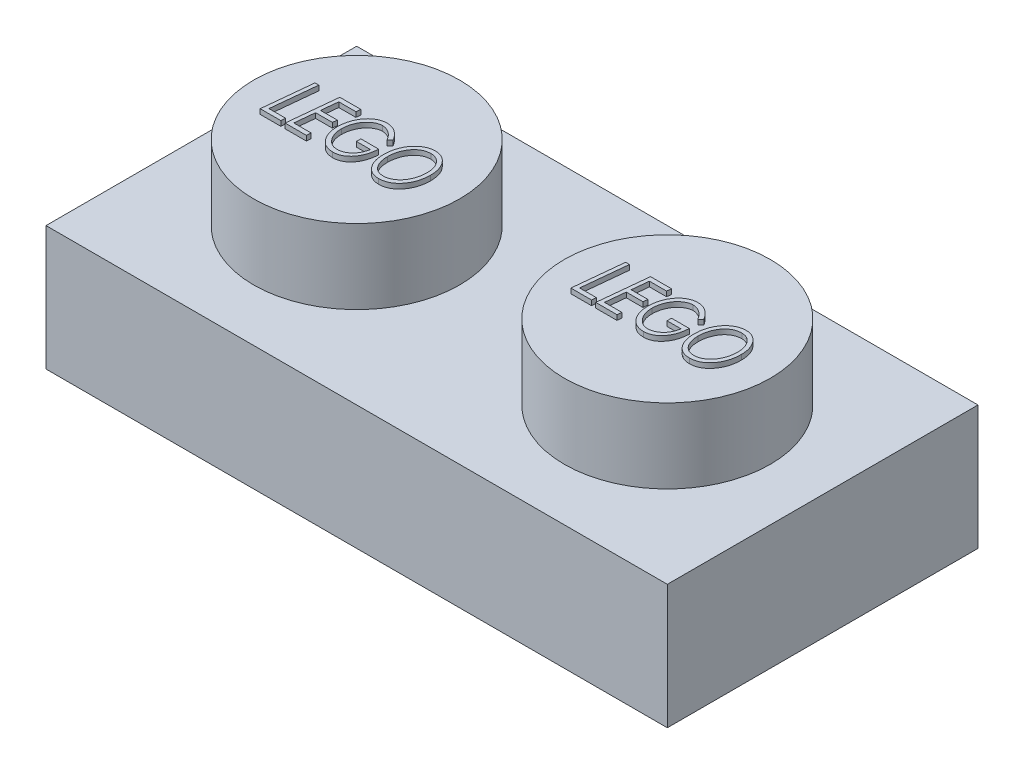
from build123d import *

# Parameters (mm, degrees)
SKETCH2_W           = 15.875
SKETCH2_H           = 7.9375
BOSS_EXTRUDE3_DEPTH = 3.175
SKETCH3_R           = 2.630752939
BOSS_EXTRUDE4_DEPTH = 1.905
LPATTERN1_COUNT     = 2
LPATTERN1_PITCH     = 7.9375
SHELL1_T            = -1.524
BOSS_EXTRUDE5_DEPTH = 0.127
LPATTERN2_COUNT     = 2
LPATTERN2_PITCH     = 7.9375
SKETCH5_R           = 1.4986
SKETCH5_R_2         = 0.635
BOSS_EXTRUDE6_DEPTH = 1.651


with BuildPart() as part:
    # Sketch2 → Boss-Extrude3 (new body)
    with BuildSketch(Plane(origin=(0, 0, 0), x_dir=(1, 0, 0), z_dir=(0, 1, 0))):
        with Locations((-9.795613381, 4.754641089)):
            Rectangle(SKETCH2_W, SKETCH2_H)
    extrude(amount=BOSS_EXTRUDE3_DEPTH)

    # Sketch3 → Boss-Extrude4 (add)
    with BuildSketch(Plane(origin=(0, 3.175, 0), x_dir=(1, 0, 0), z_dir=(0, 1, 0))):
        with Locations((-13.764363381, 4.754641089)):
            Circle(SKETCH3_R)
    boss_extrude4 = extrude(amount=BOSS_EXTRUDE4_DEPTH)

    # LPattern1: Boss-Extrude4 ×2
    with Locations(*[(i * LPATTERN1_PITCH, 0, 0) for i in range(1, LPATTERN1_COUNT)]):
        add(boss_extrude4)

    # Shell1
    shell1_openings = [part.faces().sort_by_distance(p)[0] for p in [
        (-9.795613381, 0, -4.754641089),
    ]]
    offset(amount=SHELL1_T, openings=shell1_openings, kind=Kind.INTERSECTION)

    # Sketch4 → Boss-Extrude5 (add)
    with BuildSketch(Plane(origin=(0, 5.08, 0), x_dir=(1, 0, 0), z_dir=(0, 1, 0))):
        Polygon((-15.421955913, 5.34660841), (-15.323500384, 5.34660841), (-15.441290849, 4.190582769), (-15.01414141, 4.190582769), (-15.02533532, 4.07660841), (-15.551449102, 4.07660841), align=None)
        Polygon((-14.248885, 5.34660841), (-14.262877387, 5.232634051), (-14.699694294, 5.232634051), (-14.742943493, 4.809300718), (-14.314013205, 4.809300718), (-14.326733557, 4.695326359), (-14.754646217, 4.695326359), (-14.806036442, 4.190582769), (-14.362859359, 4.190582769), (-14.374307676, 4.07660841), (-14.916449102, 4.07660841), (-14.786701506, 5.34660841), align=None)
        with BuildLine():
            Line((-13.157987564, 5.079226599), (-13.23685375, 5.004685333))
            add(Edge.make_bspline(
                [(-13.23685375, 5.004685333), (-13.243036349, 5.014919943), (-13.255215537, 5.03508124), (-13.274843903, 5.0639219), (-13.295404966, 5.090766309), (-13.316668722, 5.115943823), (-13.338681843, 5.139287343), (-13.361588027, 5.160749301), (-13.385450265, 5.180091456), (-13.409701872, 5.197942406), (-13.434658284, 5.213660022), (-13.459747782, 5.227481566), (-13.485177989, 5.238904833), (-13.510565197, 5.248734726), (-13.536282118, 5.256136896), (-13.562187777, 5.261089256), (-13.588089761, 5.264689825), (-13.605477312, 5.265029123), (-13.614139407, 5.265198154)],
                knots=[0, 0, 0, 0, 3.5867e-05, 7.0655e-05, 0.000104594, 0.000137266, 0.00016948, 0.0002008, 0.000231355, 0.000261581, 0.000291084, 0.000319773, 0.000347439, 0.000374655, 0.000401388, 0.000427582, 0.000453742, 0.000479711, 0.000479711, 0.000479711, 0.000479711], degree=3))
            add(Edge.make_bspline(
                [(-13.614139407, 5.265198154), (-13.623817018, 5.264942089), (-13.643246281, 5.264428001), (-13.672242613, 5.260605848), (-13.70083591, 5.253771652), (-13.729278127, 5.244988175), (-13.757272205, 5.233098144), (-13.785048709, 5.218900423), (-13.812373825, 5.20184576), (-13.839460855, 5.182752056), (-13.865426178, 5.16117013), (-13.890266569, 5.13792049), (-13.91359838, 5.112994152), (-13.935710508, 5.086452282), (-13.955872189, 5.057845897), (-13.975112242, 5.027830316), (-13.992587445, 4.995991744), (-14.008566347, 4.962671117), (-14.023015409, 4.928317995), (-14.035508966, 4.893155428), (-14.045942052, 4.857372561), (-14.054589121, 4.820944025), (-14.06149942, 4.783854091), (-14.066312673, 4.746142046), (-14.069143076, 4.707836031), (-14.069568079, 4.682101861), (-14.069782435, 4.669122433)],
                knots=[0, 0, 0, 0, 2.903e-05, 5.8283e-05, 8.7534e-05, 0.000117144, 0.000147477, 0.000178653, 0.000210636, 0.000244026, 0.000278, 0.000311837, 0.000346034, 0.000380367, 0.000415383, 0.000450953, 0.000487277, 0.000524259, 0.000561774, 0.000599029, 0.000636142, 0.000673537, 0.00071131, 0.000749271, 0.000787535, 0.000826472, 0.000826472, 0.000826472, 0.000826472], degree=3))
            add(Edge.make_bspline(
                [(-14.069782435, 4.669122433), (-14.069477418, 4.651721569), (-14.068877636, 4.617504752), (-14.063037479, 4.567164063), (-14.053971473, 4.518756671), (-14.041310983, 4.472223428), (-14.024646127, 4.42784351), (-14.004569657, 4.385349364), (-13.980409537, 4.345047805), (-13.953305264, 4.306998763), (-13.923509762, 4.272231716), (-13.891611692, 4.241833165), (-13.858241554, 4.215836332), (-13.822960448, 4.194859762), (-13.786317389, 4.177985595), (-13.747701019, 4.166780357), (-13.707804487, 4.159194772), (-13.680575585, 4.158413751), (-13.666801666, 4.158018667)],
                knots=[0, 0, 0, 0, 5.2184e-05, 0.000102614, 0.000151811, 0.000199829, 0.000247083, 0.000293853, 0.000340625, 0.000387856, 0.000433855, 0.000477763, 0.000519845, 0.000560465, 0.000600659, 0.0006405, 0.000680822, 0.0007221, 0.0007221, 0.0007221, 0.0007221], degree=3))
            add(Edge.make_bspline(
                [(-13.666801666, 4.158018667), (-13.650119891, 4.158598006), (-13.616764989, 4.159756384), (-13.567583001, 4.170959003), (-13.519199429, 4.187625511), (-13.472815147, 4.211693168), (-13.428975753, 4.24107788), (-13.3888146, 4.275137052), (-13.353443755, 4.314132031), (-13.322014522, 4.35741319), (-13.295472287, 4.406100752), (-13.27204085, 4.459501556), (-13.253441597, 4.518549092), (-13.244174766, 4.559989791), (-13.23939782, 4.581352)],
                knots=[0, 0, 0, 0, 4.9973e-05, 9.9921e-05, 0.000150611, 0.000203177, 0.000256167, 0.000308679, 0.000360721, 0.000413748, 0.000468753, 0.000526746, 0.000588456, 0.000654111, 0.000654111, 0.000654111, 0.000654111], degree=3))
            Line((-13.23939782, 4.581352), (-13.597602948, 4.581352))
            Line((-13.597602948, 4.581352), (-13.597602948, 4.695326359))
            Line((-13.597602948, 4.695326359), (-13.141705512, 4.695326359))
            add(Edge.make_bspline(
                [(-13.141705512, 4.695326359), (-13.143220249, 4.671630935), (-13.14618471, 4.625257073), (-13.156473523, 4.557663764), (-13.169882793, 4.493369383), (-13.188032162, 4.432650411), (-13.210191974, 4.37537214), (-13.236456597, 4.321477624), (-13.266757599, 4.270933421), (-13.300959259, 4.224225256), (-13.338414001, 4.182195788), (-13.37822362, 4.145176879), (-13.420442551, 4.113917018), (-13.464913787, 4.088167818), (-13.511934995, 4.06856876), (-13.561029266, 4.05415967), (-13.612484302, 4.045619356), (-13.647519936, 4.044574047), (-13.665275224, 4.044044308)],
                knots=[0, 0, 0, 0, 7.12e-05, 0.000139344, 0.00020491, 0.000268096, 0.00032923, 0.000388964, 0.000447735, 0.000505793, 0.000562373, 0.000616384, 0.000668589, 0.000719646, 0.000770156, 0.000821037, 0.000872858, 0.000926102, 0.000926102, 0.000926102, 0.000926102], degree=3))
            add(Edge.make_bspline(
                [(-13.665275224, 4.044044308), (-13.683458795, 4.044552296), (-13.719178417, 4.045550182), (-13.771372456, 4.054296421), (-13.821069071, 4.067841152), (-13.868065514, 4.087506656), (-13.912556407, 4.112374207), (-13.953984263, 4.143464588), (-13.993154071, 4.179412869), (-14.029026836, 4.220871562), (-14.061293356, 4.26652386), (-14.090007965, 4.315160597), (-14.113916063, 4.366865748), (-14.133555901, 4.421262957), (-14.148827293, 4.478548833), (-14.159713516, 4.538607223), (-14.166095756, 4.601566492), (-14.167008525, 4.644430286), (-14.167474743, 4.666323955)],
                knots=[0, 0, 0, 0, 5.4515e-05, 0.000107089, 0.00015832, 0.000208732, 0.000259537, 0.000310826, 0.000363759, 0.000418756, 0.000474947, 0.000531277, 0.000587959, 0.00064558, 0.000704576, 0.000765604, 0.000828511, 0.000894188, 0.000894188, 0.000894188, 0.000894188], degree=3))
            add(Edge.make_bspline(
                [(-14.167474743, 4.666323955), (-14.167185589, 4.682101713), (-14.16661133, 4.713436248), (-14.163381594, 4.759994442), (-14.157432775, 4.805749539), (-14.149274332, 4.850644315), (-14.139160769, 4.894945835), (-14.126422318, 4.938327925), (-14.111352878, 4.98094547), (-14.094155797, 5.022494256), (-14.074869439, 5.062577802), (-14.053847868, 5.100800933), (-14.03078607, 5.136684011), (-14.006484206, 5.170754132), (-13.979939226, 5.202226268), (-13.951836475, 5.231556391), (-13.922318071, 5.259016319), (-13.890824475, 5.283795413), (-13.858123028, 5.306042524), (-13.824881044, 5.325834039), (-13.790743443, 5.34211596), (-13.756112763, 5.355771227), (-13.720646944, 5.366079712), (-13.684726153, 5.373904452), (-13.648081628, 5.378221983), (-13.623478046, 5.378854133), (-13.611086522, 5.379172513)],
                knots=[0, 0, 0, 0, 4.7337e-05, 9.4011e-05, 0.000139924, 0.000185684, 0.000230857, 0.000276183, 0.000321242, 0.000366409, 0.000411014, 0.000454628, 0.000497184, 0.000538913, 0.000580086, 0.000620572, 0.000660721, 0.00070093, 0.000740658, 0.000779316, 0.000816866, 0.000854, 0.000890868, 0.000927543, 0.000964179, 0.001001354, 0.001001354, 0.001001354, 0.001001354], degree=3))
            add(Edge.make_bspline(
                [(-13.611086522, 5.379172513), (-13.599885481, 5.378887615), (-13.577690409, 5.378323085), (-13.544759644, 5.375041802), (-13.512580278, 5.369229816), (-13.481226926, 5.36060081), (-13.450309917, 5.350370482), (-13.420236456, 5.337162127), (-13.39072561, 5.322040578), (-13.362124517, 5.304229546), (-13.334002379, 5.284471776), (-13.306931369, 5.261858803), (-13.280001622, 5.237508559), (-13.254169985, 5.210414835), (-13.228831131, 5.181124192), (-13.20464202, 5.149192743), (-13.18043895, 5.115396141), (-13.16557029, 5.091442492), (-13.157987564, 5.079226599)],
                knots=[0, 0, 0, 0, 3.3606e-05, 6.6591e-05, 9.9176e-05, 0.000131574, 0.000164077, 0.000196781, 0.000230006, 0.000263473, 0.000297779, 0.000333024, 0.000369219, 0.000406644, 0.000445248, 0.000485345, 0.000526779, 0.000569901, 0.000569901, 0.000569901, 0.000569901], degree=3))
        make_face()
        with BuildLine():
            add(Edge.make_bspline(
                [(-12.369325705, 5.379172513), (-12.353010143, 5.378720522), (-12.32085994, 5.377829863), (-12.273715249, 5.369659659), (-12.22864765, 5.356507424), (-12.185856311, 5.337650018), (-12.145072326, 5.313842859), (-12.10647493, 5.284550539), (-12.070049375, 5.250024202), (-12.036169842, 5.210647693), (-12.00531375, 5.167406166), (-11.978235129, 5.120902684), (-11.955360597, 5.071642915), (-11.936357429, 5.019696609), (-11.921887955, 4.964835989), (-11.911994605, 4.907187182), (-11.905270318, 4.84685662), (-11.904608097, 4.805673345), (-11.904269615, 4.784623234)],
                knots=[0, 0, 0, 0, 4.8912e-05, 9.6383e-05, 0.000143072, 0.00018944, 0.000236302, 0.000284436, 0.000334467, 0.000386593, 0.000440034, 0.000493616, 0.000547793, 0.000602762, 0.000659349, 0.000717739, 0.000778115, 0.000841241, 0.000841241, 0.000841241, 0.000841241], degree=3))
            add(Edge.make_bspline(
                [(-11.904269615, 4.784623234), (-11.904724813, 4.758992871), (-11.905619371, 4.708623908), (-11.913649979, 4.634691374), (-11.926918957, 4.563951657), (-11.945042207, 4.49615546), (-11.969268607, 4.431731122), (-11.997812291, 4.369990143), (-12.032508136, 4.311855249), (-12.071636526, 4.257287391), (-12.11438555, 4.207292778), (-12.160684455, 4.163785264), (-12.209491268, 4.12681072), (-12.260952984, 4.096525947), (-12.315022525, 4.072933007), (-12.371712054, 4.05602052), (-12.43112154, 4.045889546), (-12.47164277, 4.044665448), (-12.49220431, 4.044044308)],
                knots=[0, 0, 0, 0, 7.6873e-05, 0.000151071, 0.000222773, 0.000292635, 0.000361299, 0.000429016, 0.000496426, 0.000564063, 0.000630262, 0.000693435, 0.00075429, 0.000813586, 0.000872147, 0.000930825, 0.000990675, 0.00105233, 0.00105233, 0.00105233, 0.00105233], degree=3))
            add(Edge.make_bspline(
                [(-12.49220431, 4.044044308), (-12.509616292, 4.04451494), (-12.543682005, 4.04543571), (-12.593480052, 4.053188575), (-12.640452828, 4.066244037), (-12.684989099, 4.084066344), (-12.726670432, 4.107489433), (-12.765818741, 4.135865921), (-12.802122503, 4.169487075), (-12.83534682, 4.207966726), (-12.865201071, 4.250535984), (-12.891189794, 4.296615807), (-12.91347966, 4.345682347), (-12.931507817, 4.398084844), (-12.945433182, 4.453595942), (-12.955221104, 4.512216375), (-12.961524863, 4.573921358), (-12.962237892, 4.616189815), (-12.962602948, 4.637830365)],
                knots=[0, 0, 0, 0, 5.2215e-05, 0.000102157, 0.000150733, 0.000198212, 0.000245705, 0.000293794, 0.000342944, 0.000393802, 0.000446031, 0.000498666, 0.000552293, 0.000607486, 0.000664684, 0.000723782, 0.000785651, 0.000850556, 0.000850556, 0.000850556, 0.000850556], degree=3))
            add(Edge.make_bspline(
                [(-12.962602948, 4.637830365), (-12.962348656, 4.654713021), (-12.961844621, 4.68817633), (-12.958119133, 4.737832996), (-12.952514622, 4.786550271), (-12.943616351, 4.83402181), (-12.933066316, 4.8806248), (-12.919782503, 4.926031082), (-12.904304725, 4.970508016), (-12.88616901, 5.013561667), (-12.866377445, 5.055186009), (-12.843997862, 5.094446642), (-12.820275911, 5.131646309), (-12.79433308, 5.166341896), (-12.767012283, 5.199072462), (-12.737321482, 5.229081319), (-12.705989763, 5.256911788), (-12.672917443, 5.282323432), (-12.638580562, 5.305193307), (-12.602929741, 5.324828759), (-12.566454338, 5.341794401), (-12.528918438, 5.355489869), (-12.490336002, 5.365956739), (-12.450894272, 5.373598515), (-12.410399159, 5.378302894), (-12.383076102, 5.378881385), (-12.369325705, 5.379172513)],
                knots=[0, 0, 0, 0, 5.0643e-05, 0.00010038, 0.000149323, 0.000197677, 0.000245196, 0.000292617, 0.000339526, 0.000386395, 0.000432706, 0.000477705, 0.000521881, 0.000564978, 0.000607585, 0.000649681, 0.000691492, 0.000733218, 0.000774708, 0.000815134, 0.000855202, 0.000895282, 0.000934843, 0.000975008, 0.001015717, 0.001056959, 0.001056959, 0.001056959, 0.001056959], degree=3))
        make_face()
        with BuildLine():
            add(Edge.make_bspline(
                [(-12.37059774, 5.265198154), (-12.382313596, 5.264974538), (-12.405384953, 5.264534185), (-12.43952799, 5.260405022), (-12.472806234, 5.254641281), (-12.50500305, 5.2453884), (-12.53641925, 5.23449868), (-12.566541003, 5.220073421), (-12.596086752, 5.204049224), (-12.624325369, 5.185085614), (-12.651275466, 5.163901314), (-12.677105719, 5.1407675), (-12.701242778, 5.115240955), (-12.723914887, 5.087622005), (-12.745319033, 5.058107871), (-12.765258418, 5.02643651), (-12.783453767, 4.992497975), (-12.800435903, 4.956872571), (-12.815618513, 4.919838387), (-12.828923446, 4.882001808), (-12.839728639, 4.843441788), (-12.848995625, 4.804516904), (-12.856130352, 4.764939705), (-12.861169544, 4.724771762), (-12.864339072, 4.683929196), (-12.8647191, 4.656492627), (-12.864910641, 4.642664099)],
                knots=[0, 0, 0, 0, 3.5131e-05, 6.9182e-05, 0.000103064, 0.000136333, 0.000169567, 0.000202688, 0.000236393, 0.000270332, 0.000304582, 0.000339169, 0.000374259, 0.000409863, 0.000446299, 0.000483568, 0.000522044, 0.000561759, 0.000601917, 0.000642065, 0.000682008, 0.000721995, 0.000762067, 0.000802584, 0.000843403, 0.000884884, 0.000884884, 0.000884884, 0.000884884], degree=3))
            add(Edge.make_bspline(
                [(-12.864910641, 4.642664099), (-12.864307988, 4.619656102), (-12.863131603, 4.574744224), (-12.854429419, 4.509171597), (-12.839695903, 4.447271889), (-12.822395219, 4.398577377), (-12.806018379, 4.361918699), (-12.792619836, 4.336186177), (-12.777779937, 4.312362342), (-12.762246178, 4.289966829), (-12.745390246, 4.269317365), (-12.727389498, 4.250238819), (-12.708171153, 4.232904881), (-12.688073445, 4.216982903), (-12.666766853, 4.20305699), (-12.644505145, 4.191085763), (-12.621414016, 4.180768501), (-12.597334266, 4.172401088), (-12.572284701, 4.166087649), (-12.546442494, 4.161495703), (-12.519659259, 4.158635539), (-12.50145487, 4.158226513), (-12.49220431, 4.158018667)],
                knots=[0, 0, 0, 0, 6.9012e-05, 0.000134712, 0.000198022, 0.000259579, 0.000289414, 0.000318432, 0.000346532, 0.000373564, 0.000400145, 0.00042642, 0.000452175, 0.000477724, 0.000503267, 0.000528424, 0.00055348, 0.000579065, 0.000604796, 0.000630896, 0.000657755, 0.000685504, 0.000685504, 0.000685504, 0.000685504], degree=3))
            add(Edge.make_bspline(
                [(-12.49220431, 4.158018667), (-12.481164543, 4.158226379), (-12.45926255, 4.158638462), (-12.426815915, 4.163069526), (-12.394912776, 4.169171543), (-12.363753517, 4.178557501), (-12.333054523, 4.1901992), (-12.30315314, 4.204836709), (-12.27362727, 4.221656145), (-12.245054493, 4.241259996), (-12.217396148, 4.263059149), (-12.191102552, 4.2869402), (-12.166751424, 4.31313992), (-12.143343282, 4.340857537), (-12.121926482, 4.370957713), (-12.101553921, 4.402800133), (-12.083509498, 4.437043875), (-12.066362584, 4.472756352), (-12.051268705, 4.510002211), (-12.037904005, 4.548157353), (-12.027111895, 4.587233797), (-12.017881689, 4.626845971), (-12.010718503, 4.667266057), (-12.005706916, 4.708370092), (-12.002526277, 4.750312827), (-12.002151397, 4.778511748), (-12.001961923, 4.79276426)],
                knots=[0, 0, 0, 0, 3.3097e-05, 6.5662e-05, 9.8093e-05, 0.000130454, 0.000163149, 0.000196488, 0.000230221, 0.000265008, 0.000300331, 0.000335806, 0.000371442, 0.000407566, 0.000444563, 0.000482183, 0.000520883, 0.000560598, 0.000600991, 0.00064138, 0.000681813, 0.000722543, 0.000763366, 0.000804893, 0.000846727, 0.000889479, 0.000889479, 0.000889479, 0.000889479], degree=3))
            add(Edge.make_bspline(
                [(-12.001961923, 4.79276426), (-12.002383429, 4.811264), (-12.003207157, 4.847417056), (-12.008729979, 4.900202516), (-12.018384404, 4.949996074), (-12.031884335, 4.996843587), (-12.049147304, 5.040781654), (-12.070413266, 5.081809748), (-12.095511146, 5.119934561), (-12.115257706, 5.142857206), (-12.125094935, 5.15427668)],
                knots=[0, 0, 0, 0, 5.5498e-05, 0.000108457, 0.000158999, 0.000207469, 0.000254523, 0.000300379, 0.00034589, 0.00039107, 0.00039107, 0.00039107, 0.00039107], degree=3))
            add(Edge.make_bspline(
                [(-12.125094935, 5.15427668), (-12.133669324, 5.163096064), (-12.150521626, 5.180429887), (-12.178137379, 5.203115094), (-12.206989058, 5.222389045), (-12.237249627, 5.237947562), (-12.268734009, 5.250365639), (-12.301624315, 5.258916547), (-12.335745739, 5.264150728), (-12.358876291, 5.264845883), (-12.37059774, 5.265198154)],
                knots=[0, 0, 0, 0, 3.6878e-05, 7.2482e-05, 0.000106986, 0.00014078, 0.00017437, 0.000208309, 0.000242526, 0.000277679, 0.000277679, 0.000277679, 0.000277679], degree=3))
        make_face(mode=Mode.SUBTRACT)
    boss_extrude5 = extrude(amount=BOSS_EXTRUDE5_DEPTH)

    # LPattern2: Boss-Extrude5 ×2
    with Locations(*[(i * LPATTERN2_PITCH, 0, 0) for i in range(1, LPATTERN2_COUNT)]):
        add(boss_extrude5)

    # Sketch5 → Boss-Extrude6 (add)
    with BuildSketch(Plane.XZ):
        with Locations((-9.795613381, -4.754641089)):
            Circle(SKETCH5_R)
        with Locations((-9.795613381, -4.754641089)):
            Circle(SKETCH5_R_2, mode=Mode.SUBTRACT)
    extrude(amount=-BOSS_EXTRUDE6_DEPTH)


solid = part.part
